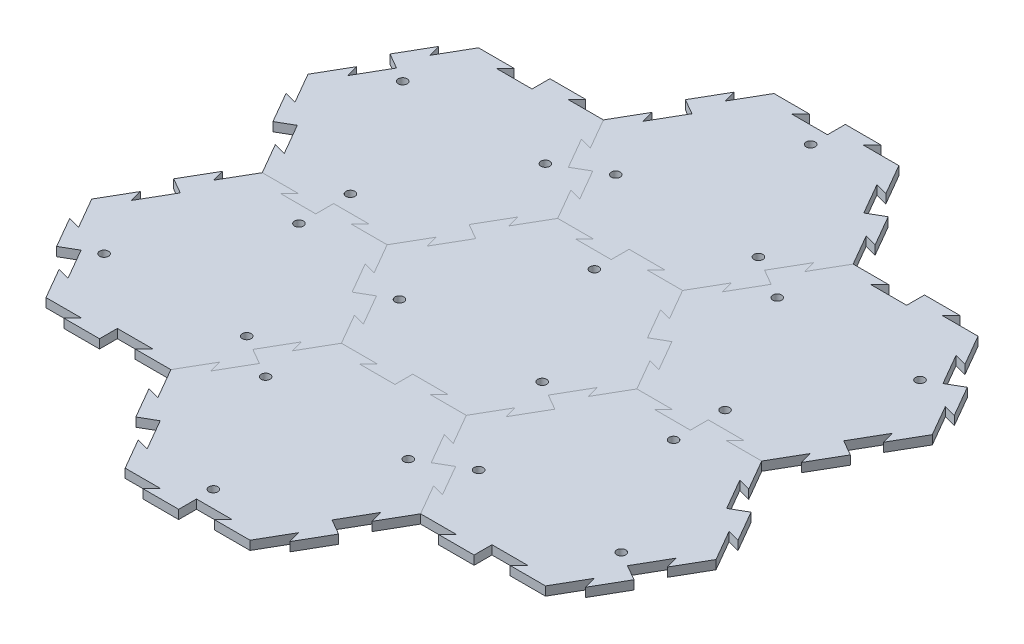
from build123d import *

# Parameters (mm, degrees)
BOSS_EXTRUDE1_DEPTH = 6.35
SKETCH9_R           = 3.175
CUT_EXTRUDE3_DEPTH  = 7.35
CIRPATTERN6_COUNT   = 3
CUT_EXTRUDE4_DEPTH  = 7.35
BOSS_EXTRUDE4_DEPTH = 6.35
CIRPATTERN7_COUNT   = 6
LPATTERN1_COUNT     = 2
LPATTERN1_PITCH     = 153.979316882
CIRPATTERN8_COUNT   = 6


with BuildPart() as part:
    # Sketch1 → Boss-Extrude1 (new body)
    with BuildSketch(Plane(origin=(0, 0, 0), x_dir=(1, 0, 0), z_dir=(0, 1, 0))):
        Polygon((88.9, 0), (44.45, 76.989658396), (-44.45, 76.989658396), (-88.9, 0), (-44.45, -76.989658396), (44.45, -76.989658396), align=None)
    extrude(amount=-BOSS_EXTRUDE1_DEPTH)

    # Sketch9 → Cut-Extrude3 (cut, through all)
    with BuildSketch(Plane(origin=(0, 0, 0), x_dir=(1, 0, 0), z_dir=(0, 1, 0))):
        with Locations((-50.8, -29.329393675)):
            Circle(SKETCH9_R)
    cut_extrude3 = extrude(amount=-CUT_EXTRUDE3_DEPTH, mode=Mode.SUBTRACT)

    # CirPattern6: Cut-Extrude3 ×3 about axis
    cirpattern6_axis = Axis((0, 0, 0), (0, 1, 0))
    for i in range(1, CIRPATTERN6_COUNT):
        add(cut_extrude3.rotate(cirpattern6_axis, i * 360 / CIRPATTERN6_COUNT), mode=Mode.SUBTRACT)

    # Sketch10 → Cut-Extrude4 (cut, through all)
    with BuildSketch(Plane(origin=(0, 0, 0), x_dir=(1, 0, 0), z_dir=(0, 1, 0))):
        Polygon((57.15, 54.99261314), (48.475738686, 57.316874454), (61.175738686, 35.319829198), (66.675, 38.494829198), align=None)
    cut_extrude4 = extrude(amount=-CUT_EXTRUDE4_DEPTH, mode=Mode.SUBTRACT)

    # Sketch11 → Boss-Extrude4 (add)
    with BuildSketch(Plane(origin=(0, 0, 0), x_dir=(1, 0, 0), z_dir=(0, 1, 0))):
        Polygon((66.675, 38.494829198), (72.174261314, 41.669829198), (84.874261314, 19.672783942), (76.2, 21.997045256), align=None)
    boss_extrude4 = extrude(amount=-BOSS_EXTRUDE4_DEPTH)

    # CirPattern7: Cut-Extrude4, Boss-Extrude4 ×6 about axis
    cirpattern7_axis = Axis((0, 0, 0), (0, 1, 0))
    for i in range(1, CIRPATTERN7_COUNT):
        add(cut_extrude4.rotate(cirpattern7_axis, i * 360 / CIRPATTERN7_COUNT), mode=Mode.SUBTRACT)
        add(boss_extrude4.rotate(cirpattern7_axis, i * 360 / CIRPATTERN7_COUNT))


with BuildPart() as lpattern1_1:
    # LPattern1: pattern copy
    add(part.part.moved(Location(Vector(0.866025404, 0, 0.5) * (1 * LPATTERN1_PITCH))))


with BuildPart() as cirpattern8_1:
    # CirPattern8: pattern copy
    add(lpattern1_1.part.rotate(Axis((0, 0, 0), (0, 1, 0)), 1 * 360 / CIRPATTERN8_COUNT))


with BuildPart() as cirpattern8_2:
    # CirPattern8: pattern copy
    add(lpattern1_1.part.rotate(Axis((0, 0, 0), (0, 1, 0)), 2 * 360 / CIRPATTERN8_COUNT))


with BuildPart() as cirpattern8_3:
    # CirPattern8: pattern copy
    add(lpattern1_1.part.rotate(Axis((0, 0, 0), (0, 1, 0)), 3 * 360 / CIRPATTERN8_COUNT))


with BuildPart() as cirpattern8_4:
    # CirPattern8: pattern copy
    add(lpattern1_1.part.rotate(Axis((0, 0, 0), (0, 1, 0)), 4 * 360 / CIRPATTERN8_COUNT))


with BuildPart() as cirpattern8_5:
    # CirPattern8: pattern copy
    add(lpattern1_1.part.rotate(Axis((0, 0, 0), (0, 1, 0)), 5 * 360 / CIRPATTERN8_COUNT))


solid = Compound([part.part, lpattern1_1.part, cirpattern8_1.part, cirpattern8_2.part, cirpattern8_3.part, cirpattern8_4.part, cirpattern8_5.part])
